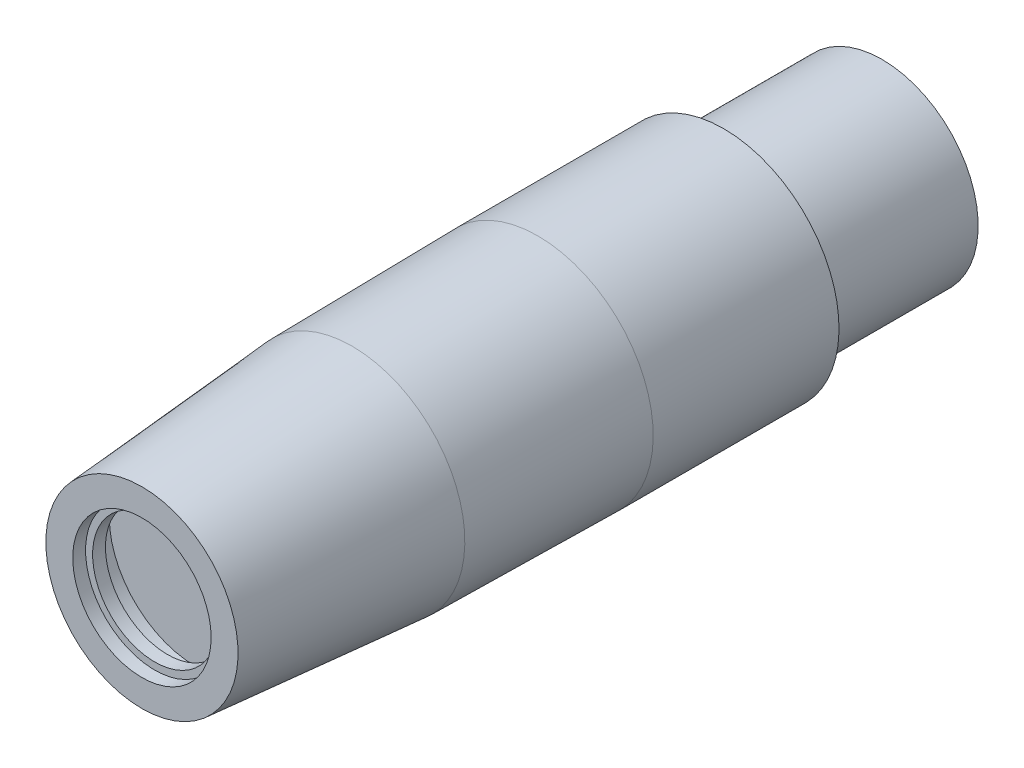
from build123d import *

# Parameters (mm, degrees)
CUT_EXTRUDE1_DEPTH = 0.75
SKETCH3_R          = 5.4
CUT_EXTRUDE2_DEPTH = 1
SKETCH4_R          = 4.85
CUT_EXTRUDE3_DEPTH = 1
SKETCH5_R          = 6.75
CUT_EXTRUDE4_DEPTH = 2.2


with BuildPart() as part:
    # Sketch1 → Revolve1 (revolve)
    with BuildSketch(Plane(origin=(0, 0, 0), x_dir=(0, 0, -1), z_dir=(1, 0, 0))):
        Polygon((0, 0), (0, 7.5), (16.4, 8.8), (30.9, 9), (45.4, 9), (45.4, 7.5), (57.76, 7.5), (57.76, 6.125), (58.51, 6.125), (58.51, 0), align=None)
    revolve(axis=Axis((0, 0, -58.51), (0, 0, 1)))

    # Sketch2 → Cut-Extrude1 (cut)
    with BuildSketch(Plane(origin=(0, 0, -58.51), x_dir=(-1, 0, 0), z_dir=(0, 0, -1))):
        with BuildLine():
            Line((-3.836013556, 4.775), (3.836013556, 4.775))
            ThreePointArc((3.836013556, 4.775), (0, 6.125), (-3.836013556, 4.775))
        make_face()
    extrude(amount=-CUT_EXTRUDE1_DEPTH, mode=Mode.SUBTRACT)

    # Sketch3 → Cut-Extrude2 (cut)
    with BuildSketch(Plane.XY):
        Circle(SKETCH3_R)
    extrude(amount=-CUT_EXTRUDE2_DEPTH, mode=Mode.SUBTRACT)

    # Sketch4 → Cut-Extrude3 (cut)
    with BuildSketch(Plane.XY.offset(-1)):
        Circle(SKETCH4_R)
    extrude(amount=-CUT_EXTRUDE3_DEPTH, mode=Mode.SUBTRACT)

    # Sketch5 → Cut-Extrude4 (cut)
    with BuildSketch(Plane.XY.offset(-2)):
        Circle(SKETCH5_R)
    extrude(amount=-CUT_EXTRUDE4_DEPTH, mode=Mode.SUBTRACT)


solid = part.part
